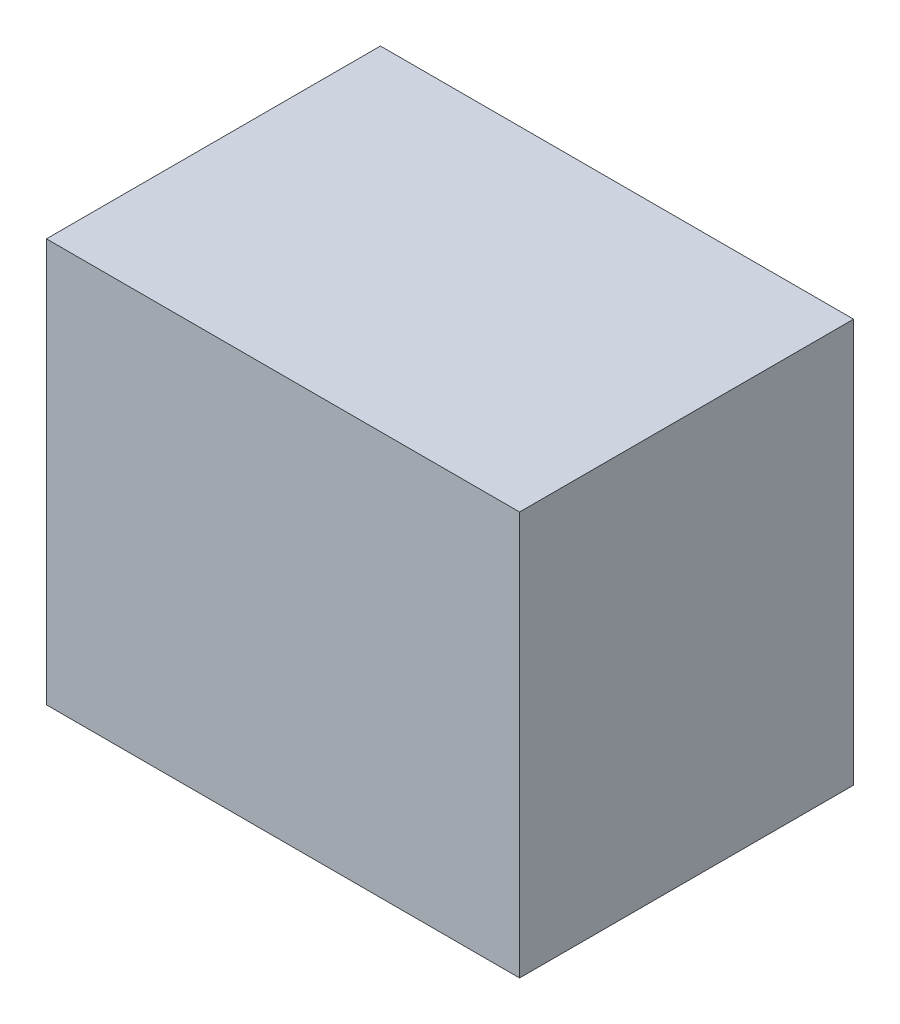
from build123d import *

# Parameters (mm, degrees)
SKETCH1_W           = 340
SKETCH1_H           = 240
BOSS_EXTRUDE1_DEPTH = 290


with BuildPart() as part:
    # Sketch1 → Boss-Extrude1 (new body)
    with BuildSketch(Plane(origin=(0, 0, 0), x_dir=(1, 0, 0), z_dir=(0, 1, 0))):
        Rectangle(SKETCH1_W, SKETCH1_H)
    extrude(amount=BOSS_EXTRUDE1_DEPTH)


solid = part.part
